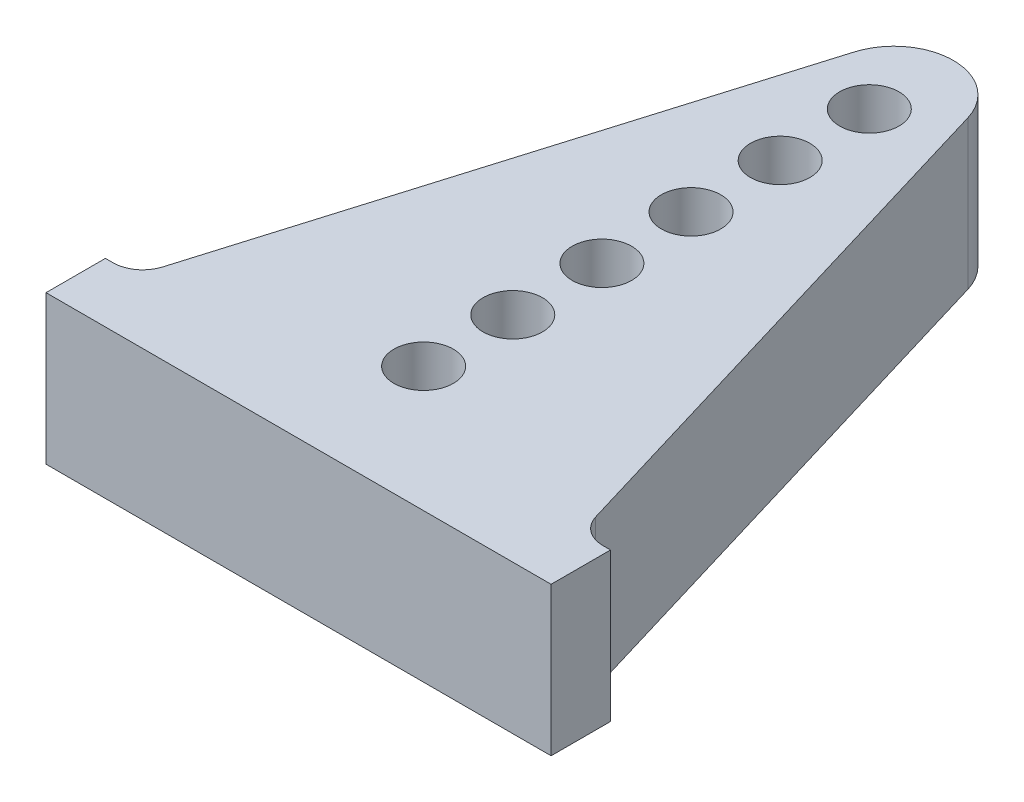
from build123d import *

# Parameters (mm, degrees)
SKETCH1_R           = 1
BOSS_EXTRUDE1_DEPTH = 2.5


with BuildPart() as part:
    # Sketch1 → Boss-Extrude1 (new body, symmetric)
    with BuildSketch(Plane(origin=(0, 0, 0), x_dir=(1, 0, 0), z_dir=(0, 1, 0))):
        with BuildLine():
            Line((-2.892231872, 13.10273237), (-8.262783668, -4.799106947))
            ThreePointArc((-8.262783668, -4.799106947), (-8.623679423, -5.31405199), (-9.220609953, -5.511759062))
            Line((-9.220609953, -5.511759062), (-9.476579302, -5.511759062))
            Line((-9.476579302, -5.511759062), (-9.476579302, -7.511759062))
            Line((-9.476579302, -7.511759062), (7.523420698, -7.511759062))
            Line((7.523420698, -7.511759062), (7.523420698, -5.511759062))
            Line((7.523420698, -5.511759062), (7.267451349, -5.511759062))
            ThreePointArc((7.267451349, -5.511759062), (6.670520819, -5.31405199), (6.309625064, -4.799106947))
            Line((6.309625064, -4.799106947), (0.939073269, 13.10273237))
            ThreePointArc((0.939073269, 13.10273237), (-0.976579302, 14.528036599), (-2.892231872, 13.10273237))
        make_face()
        with Locations((-0.976579302, -3.301730431)):
            Circle(SKETCH1_R, mode=Mode.SUBTRACT)
        with Locations((-0.976579302, -0.301730431)):
            Circle(SKETCH1_R, mode=Mode.SUBTRACT)
        with Locations((-0.976579302, 2.698269569)):
            Circle(SKETCH1_R, mode=Mode.SUBTRACT)
        with Locations((-0.976579302, 8.698269569)):
            Circle(SKETCH1_R, mode=Mode.SUBTRACT)
        with Locations((-0.976579302, 11.698269569)):
            Circle(SKETCH1_R, mode=Mode.SUBTRACT)
        with Locations((-0.976579302, 5.698269569)):
            Circle(SKETCH1_R, mode=Mode.SUBTRACT)
    extrude(amount=BOSS_EXTRUDE1_DEPTH, both=True)


solid = part.part
